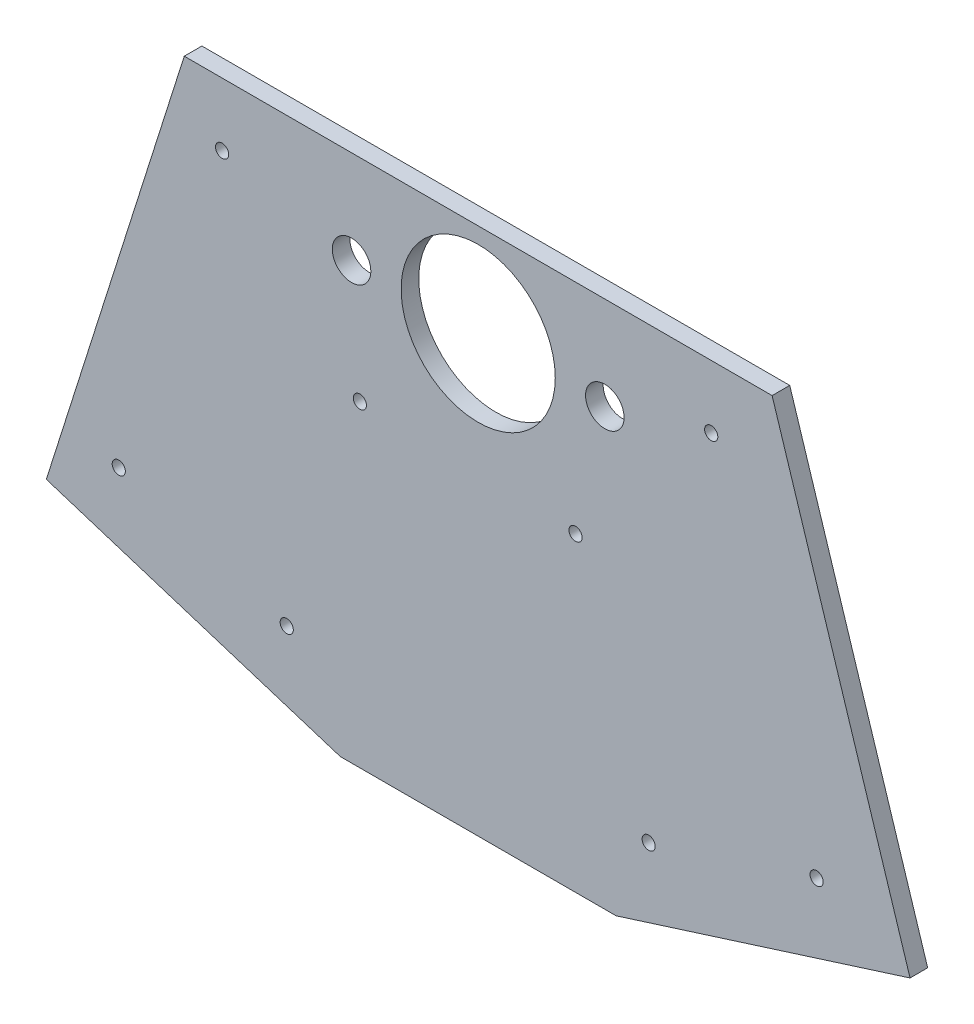
from build123d import *

# Parameters (mm, degrees)
BOSS_EXTRUDE1_DEPTH   = 5.08
SKETCH2_R             = 22.225
SKETCH2_R_2           = 5.55625
CUT_EXTRUDE1_DEPTH    = 6.08
F_6_CLEARANCE_HOLE1_D = 3.7973


with BuildPart() as part:
    # Sketch1 → Boss-Extrude1 (new body)
    with BuildSketch(Plane.XY):
        Polygon((-84.749075787, 26.84779606), (84.749075787, 26.84779606), (124.522960457, -98.704407881), (39.77388467, -125.55220394), (-39.77388467, -125.55220394), (-124.522960457, -98.704407881), align=None)
    extrude(amount=BOSS_EXTRUDE1_DEPTH)

    # Sketch2 → Cut-Extrude1 (cut, through all)
    with BuildSketch(Plane.XY.offset(5.08)):
        Circle(SKETCH2_R)
        with Locations((-36.5125, 0)):
            Circle(SKETCH2_R_2)
        with Locations((36.5125, 0)):
            Circle(SKETCH2_R_2)
    extrude(amount=-CUT_EXTRUDE1_DEPTH, mode=Mode.SUBTRACT)

    # #6 Clearance Hole1 (through all)
    with Locations(Plane.XY.offset(5.08)):
        with Locations((-73.849633462, 8.68727982), (-103.636097768, -85.338140937), (-55.208054461, -100.679738685), (-34.113357557, -34.091179139), (49.154549048, -102.597438404), (97.582592354, -87.255840656), (28.059852144, -36.008878857), (67.188616869, 8.68727982)):
            Hole(F_6_CLEARANCE_HOLE1_D / 2)


solid = part.part
